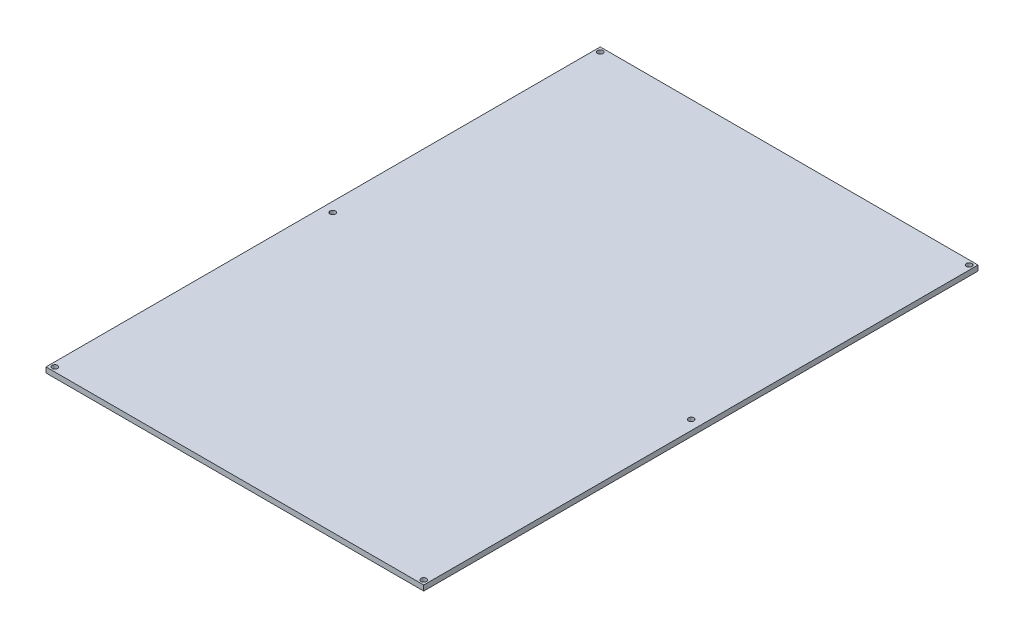
from build123d import *

# Parameters (mm, degrees)
CROQUIS1_W              = 214
CROQUIS1_H              = 314
CROQUIS1_R              = 1.55
SALIENTE_EXTRUIR1_DEPTH = 3


with BuildPart() as part:
    # Croquis1 → Saliente-Extruir1 (new body)
    with BuildSketch(Plane(origin=(0, 0, 0), x_dir=(1, 0, 0), z_dir=(0, 1, 0))):
        with Locations((107, 157)):
            Rectangle(CROQUIS1_W, CROQUIS1_H)
        with Locations((2.5, 311.5)):
            Circle(CROQUIS1_R, mode=Mode.SUBTRACT)
        with Locations((211.5, 311.5)):
            Circle(CROQUIS1_R, mode=Mode.SUBTRACT)
        with Locations((2.5, 2.5)):
            Circle(CROQUIS1_R, mode=Mode.SUBTRACT)
        with Locations((211.5, 2.5)):
            Circle(CROQUIS1_R, mode=Mode.SUBTRACT)
        with Locations((5.5, 157)):
            Circle(CROQUIS1_R, mode=Mode.SUBTRACT)
        with Locations((208.5, 157)):
            Circle(CROQUIS1_R, mode=Mode.SUBTRACT)
    extrude(amount=SALIENTE_EXTRUIR1_DEPTH)


solid = part.part
